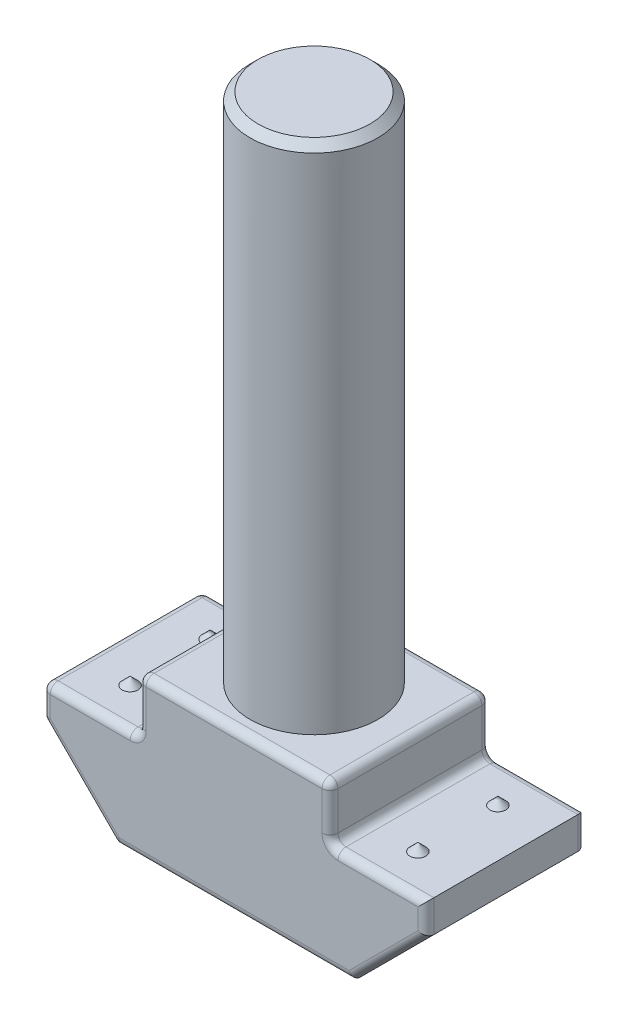
from build123d import *

# Parameters (mm, degrees)
ESTRUSIONE_ESTRUSIONE1_DEPTH = 5
RACCORDO1_R                  = 0.25
SCHIZZO7_R                   = 2
ESTRUSIONE_ESTRUSIONE3_DEPTH = 16
SMUSSO1_SIZE                 = 0.25


with BuildPart() as part:
    # Schizzo1 → Estrusione-Estrusione1 (new body)
    with BuildSketch(Plane.XY):
        Polygon((3.7, 0), (-3.7, 0), (-6, 2.3), (-6, 3.3), (-3, 3.3), (-3, 5), (3, 5), (3, 3.3), (6, 3.3), (6, 2.3), align=None)
    extrude(amount=ESTRUSIONE_ESTRUSIONE1_DEPTH)

    # Raccordo1
    raccordo1_edges = [part.edges().sort_by_distance(p)[0] for p in [
        (-6, 2.8, 0),
        (-4.5, 3.3, 0),
        (-3, 4.15, 0),
        (0, 5, 0),
        (3, 4.15, 0),
        (4.5, 3.3, 0),
        (6, 2.8, 0),
        (4.85, 1.15, 5),
        (4.85, 1.15, 0),
        (0, 0, 0),
        (-4.85, 1.15, 0),
        (6, 2.8, 5),
        (-6, 2.3, 2.5),
        (-6, 3.3, 2.5),
        (-3, 3.3, 2.5),
        (-3, 5, 2.5),
        (3, 5, 2.5),
        (3, 3.3, 2.5),
        (-3.7, 0, 2.5),
        (4.5, 3.3, 5),
        (3, 4.15, 5),
        (0, 5, 5),
        (-3, 4.15, 5),
        (-4.5, 3.3, 5),
        (-6, 2.8, 5),
        (-4.85, 1.15, 5),
        (0, 0, 5),
    ]]
    fillet(raccordo1_edges, radius=RACCORDO1_R)

    # Schizzo7 → Estrusione-Estrusione3 (add)
    with BuildSketch(Plane(origin=(0, 5, 0), x_dir=(1, 0, 0), z_dir=(0, 1, 0))):
        with Locations((0, -2.5)):
            Circle(SCHIZZO7_R)
    extrude(amount=ESTRUSIONE_ESTRUSIONE3_DEPTH)

    # Smusso1
    smusso1_edges = [part.edges().sort_by_distance(p)[0] for p in [
        (-2, 21, 2.5),
    ]]
    chamfer(smusso1_edges, length=SMUSSO1_SIZE)

    # Schizzo8 → Rivoluzione2 (revolve)
    with BuildSketch(Plane.XY.offset(1.25)):
        Polygon((-4.5, 3.3), (-4.5, 3.55), (-4.75, 3.3), align=None)
    rivoluzione2 = revolve(axis=Axis((-4.5, 3.3, 1.25), (0, 1, 0)))

    # Specchia3: Rivoluzione2 across plane
    add(rivoluzione2.mirror(Plane(origin=(0, 0, 0), x_dir=(0, 0, 1), z_dir=(1, 0, 0))))

    # Specchia4: Rivoluzione2 across plane
    add(rivoluzione2.mirror(Plane.XY.offset(2.5)))

    # Specchia4 copy 1 sketch → Specchia4 copy 1 (revolve)
    with BuildSketch(Plane(origin=(0, 0, 3.75), x_dir=(-1, 0, 0), z_dir=(0, 0, -1))):
        Polygon((-4.5, 3.3), (-4.5, 3.55), (-4.75, 3.3), align=None)
    revolve(axis=Axis((4.5, 3.3, 3.75), (0, 1, 0)))


solid = part.part
